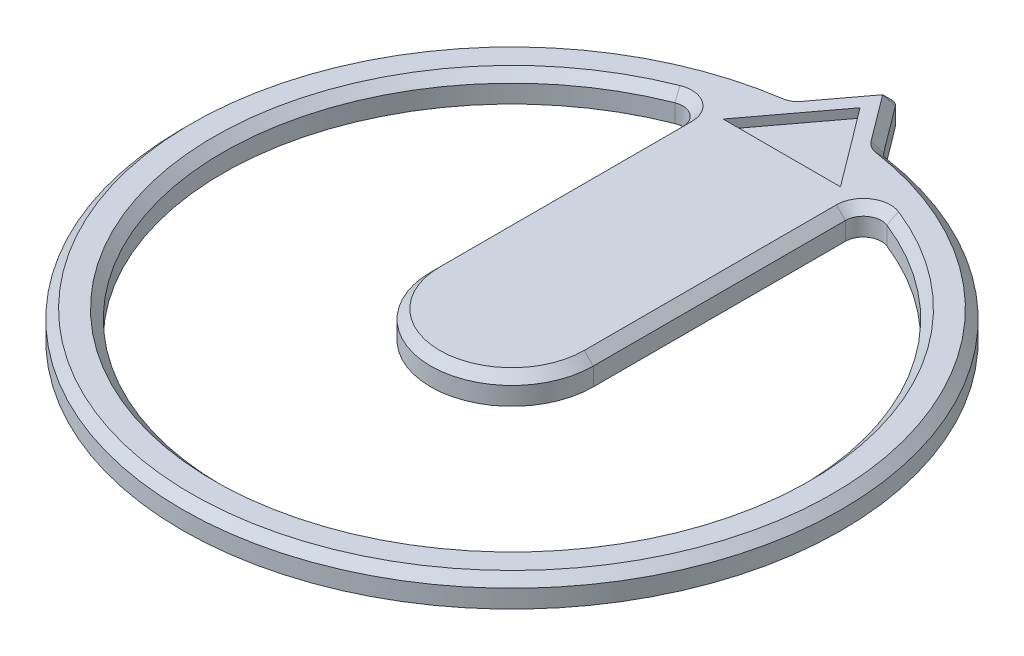
from build123d import *

# Parameters (mm, degrees)
SKETCH2_R             = 0.786234884
BOSS_EXTRUDE1_DEPTH   = 0.3
SKETCH2_R_2           = 5.5
SKETCH2_R_3           = 3.2
BOSS_EXTRUDE1_2_DEPTH = 0.3
BOSS_EXTRUDE2_DEPTH   = 0.3
SKETCH4_R             = 5.5
CUT_EXTRUDE1_DEPTH    = 1.3
FILLET1_R             = 0.2
FILLET2_R             = 0.1
CHAMFER1_SIZE         = 0.1
CUT_EXTRUDE2_DEPTH    = 0.1


with BuildPart() as part:
    # Sketch2 → Boss-Extrude1 (new body)
    with BuildSketch(Plane(origin=(0, 0, 0), x_dir=(1, 0, 0), z_dir=(0, 1, 0))):
        Circle(SKETCH2_R)
    extrude(amount=BOSS_EXTRUDE1_DEPTH)



with BuildPart() as body_2:
    # Sketch2 → Boss-Extrude1 2 (new body)
    with BuildSketch(Plane(origin=(0, 0, 0), x_dir=(1, 0, 0), z_dir=(0, 1, 0))):
        Circle(SKETCH2_R_2)
        Circle(SKETCH2_R_3, mode=Mode.SUBTRACT)
    extrude(amount=BOSS_EXTRUDE1_2_DEPTH)


with BuildPart() as part_1:
    add(part.part)

    add(body_2.part)  # Boss-Extrude2 merges body 2
    # Sketch3 → Boss-Extrude2 (add)
    with BuildSketch(Plane(origin=(0, 0.3, 0), x_dir=(1, 0, 0), z_dir=(0, 1, 0))):
        with BuildLine():
            Line((-0.9, 0), (-0.9, 3.441526045))
            Line((-0.9, 3.441526045), (0.9, 3.441526045))
            Line((0.9, 3.441526045), (0.9, 0))
            ThreePointArc((0.9, 0), (0, -0.9), (-0.9, 0))
        make_face()
    extrude(amount=-BOSS_EXTRUDE2_DEPTH)

    # Sketch4 → Cut-Extrude1 (cut, through all)
    with BuildSketch(Plane(origin=(0, 0.3, 0), x_dir=(1, 0, 0), z_dir=(0, 1, 0))):
        Circle(SKETCH4_R)
        with BuildLine():
            ThreePointArc((3.65, 0), (-2.401287493, -2.748875839), (-0.490448426, 3.616899272))
            Line((-0.490448426, 3.616899272), (0, 4.270830507))
            Line((0, 4.270830507), (0.490448426, 3.616899272))
            ThreePointArc((0.490448426, 3.616899272), (2.748875839, 2.401287493), (3.65, 0))
        make_face(mode=Mode.SUBTRACT)
    extrude(amount=-CUT_EXTRUDE1_DEPTH, mode=Mode.SUBTRACT)

    # Fillet1
    fillet1_edges = [part_1.edges().sort_by_distance(p)[0] for p in [
        (-0.9, 0.15, -3.070830507),
        (0.9, 0.15, -3.070830507),
    ]]
    fillet(fillet1_edges, radius=FILLET1_R)

    # Fillet2
    fillet2_edges = [part_1.edges().sort_by_distance(p)[0] for p in [
        (0.490448426, 0.15, -3.616899272),
        (0, 0.15, -4.270830507),
        (-0.490448426, 0.15, -3.616899272),
    ]]
    fillet(fillet2_edges, radius=FILLET2_R)

    # Chamfer1
    chamfer1_edges = [part_1.edges().sort_by_distance(p)[0] for p in [
        (0, 0.3, 3.2),
        (-0.9, 0.3, -1.395528574),
        (0.987453713, 0.3, -2.956385104),
        (-0.987453713, 0.3, -2.956385104),
        (0, 0.3, 0.9),
        (0, 0.3, 3.65),
        (0.9, 0.3, -1.395528574),
        (0.272771923, 0.3, -3.907134609),
        (-0.272771923, 0.3, -3.907134609),
        (0, 0.3, -4.20416384),
        (0.494418226, 0.3, -3.624162542),
        (-0.494418226, 0.3, -3.624162542),
    ]]
    chamfer(chamfer1_edges, length=CHAMFER1_SIZE)

    # Sketch5 → Cut-Extrude2 (cut)
    with BuildSketch(Plane(origin=(0, 0.3, 0), x_dir=(1, 0, 0), z_dir=(0, 1, 0))):
        Polygon((-0.65, 2.987497173), (0.65, 2.987497173), (0, 3.85416384), align=None)
    extrude(amount=-CUT_EXTRUDE2_DEPTH, mode=Mode.SUBTRACT)


solid = part_1.part
